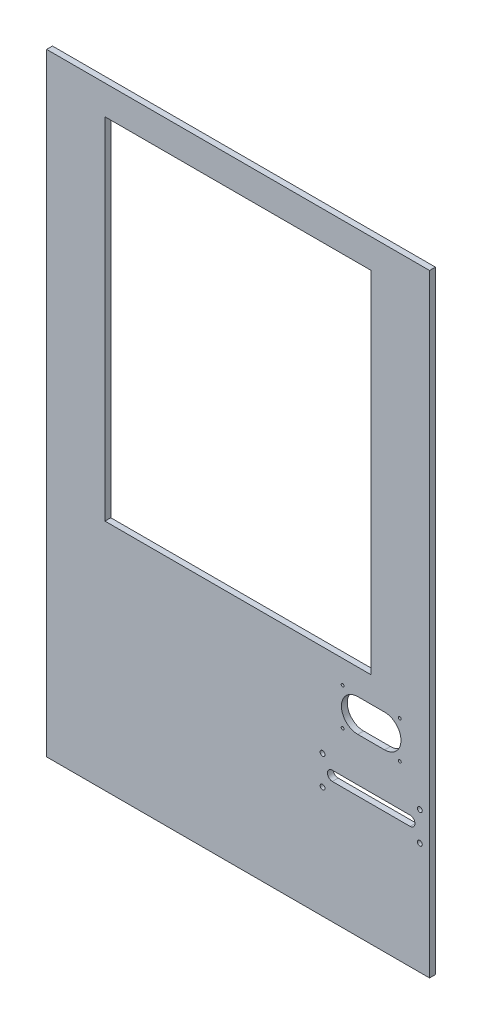
from build123d import *

# Parameters (mm, degrees)
SKETCH1_W           = 500
SKETCH1_H           = 800
SKETCH1_R           = 1.905
SKETCH1_R_2         = 3.175
SKETCH1_W_2         = 347.6
SKETCH1_H_2         = 457.2
BOSS_EXTRUDE1_DEPTH = 7.62


with BuildPart() as part:
    # Sketch1 → Boss-Extrude1 (new body)
    with BuildSketch(Plane.XY):
        Rectangle(SKETCH1_W, SKETCH1_H)
        with Locations((136.462, -125.68)):
            Circle(SKETCH1_R, mode=Mode.SUBTRACT)
        with Locations((211.138, -125.68)):
            Circle(SKETCH1_R, mode=Mode.SUBTRACT)
        with Locations((211.138, -174.448)):
            Circle(SKETCH1_R, mode=Mode.SUBTRACT)
        with Locations((136.462, -174.448)):
            Circle(SKETCH1_R, mode=Mode.SUBTRACT)
        with Locations((237.3, -215.85)):
            Circle(SKETCH1_R_2, mode=Mode.SUBTRACT)
        with Locations((110.3, -215.85)):
            Circle(SKETCH1_R_2, mode=Mode.SUBTRACT)
        with Locations((237.3, -253.95)):
            Circle(SKETCH1_R_2, mode=Mode.SUBTRACT)
        with Locations((110.3, -253.95)):
            Circle(SKETCH1_R_2, mode=Mode.SUBTRACT)
        with Locations((0, 133.3)):
            Rectangle(SKETCH1_W_2, SKETCH1_H_2, mode=Mode.SUBTRACT)
        with BuildLine():
            Line((156.274, -128.728), (191.326, -128.728))
            ThreePointArc((191.326, -128.728), (212.662, -150.064), (191.326, -171.4))
            Line((191.326, -171.4), (156.274, -171.4))
            ThreePointArc((156.274, -171.4), (134.938, -150.064), (156.274, -128.728))
        make_face(mode=Mode.SUBTRACT)
        with BuildLine():
            Line((224.6, -241.25), (123, -241.25))
            ThreePointArc((123, -241.25), (116.65, -234.9), (123, -228.55))
            Line((123, -228.55), (224.6, -228.55))
            ThreePointArc((224.6, -228.55), (230.95, -234.9), (224.6, -241.25))
        make_face(mode=Mode.SUBTRACT)
    extrude(amount=BOSS_EXTRUDE1_DEPTH)


solid = part.part
